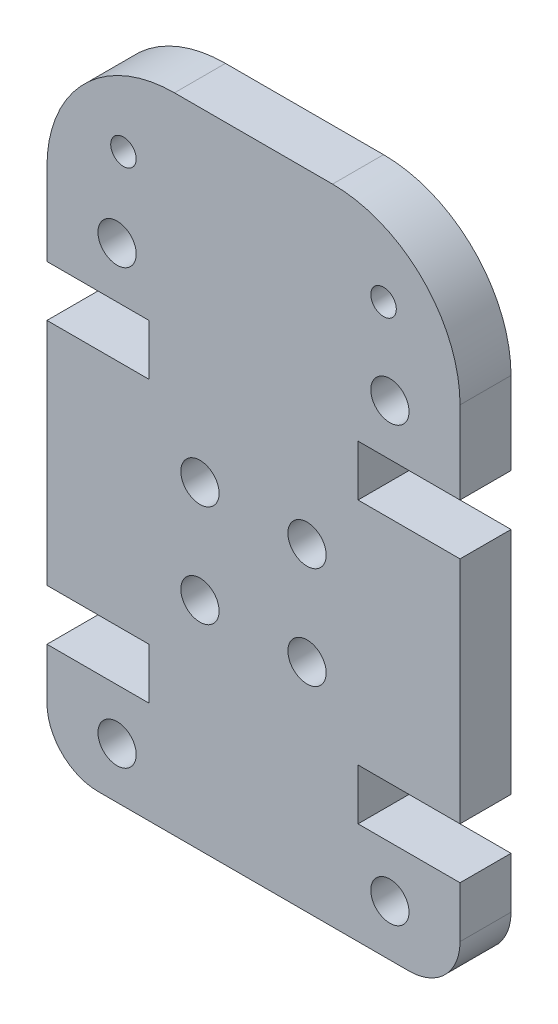
from build123d import *

# Parameters (mm, degrees)
SKETCH1_R           = 0.75
SKETCH1_R_2         = 0.5
BOSS_EXTRUDE1_DEPTH = 2


with BuildPart() as part:
    # Sketch1 → Boss-Extrude1 (new body)
    with BuildSketch(Plane.XY):
        with BuildLine():
            Line((12.2, 4), (16.2, 4))
            Line((16.2, 4), (16.2, 2))
            ThreePointArc((16.2, 2), (15.614213562, 0.585786438), (14.2, 0))
            Line((14.2, 0), (2, 0))
            ThreePointArc((2, 0), (0.585786438, 0.585786438), (0, 2))
            Line((0, 2), (0, 4))
            Line((0, 4), (4, 4))
            Line((4, 4), (4, 6))
            Line((4, 6), (0, 6))
            Line((0, 6), (0, 15))
            Line((0, 15), (4, 15))
            Line((4, 15), (4, 17))
            Line((4, 17), (0, 17))
            Line((0, 17), (0, 20.23))
            ThreePointArc((0, 20.23), (1.464466094, 23.765533906), (5, 25.23))
            Line((5, 25.23), (11.2, 25.23))
            ThreePointArc((11.2, 25.23), (14.735533906, 23.765533906), (16.2, 20.23))
            Line((16.2, 20.23), (16.2, 17))
            Line((16.2, 17), (12.2, 17))
            Line((12.2, 17), (12.2, 15))
            Line((12.2, 15), (16.2, 15))
            Line((16.2, 15), (16.2, 6))
            Line((16.2, 6), (12.2, 6))
            Line((12.2, 6), (12.2, 4))
        make_face()
        with Locations((13.45, 2)):
            Circle(SKETCH1_R, mode=Mode.SUBTRACT)
        with Locations((13.2, 22.23)):
            Circle(SKETCH1_R_2, mode=Mode.SUBTRACT)
        with Locations((10.2, 8.5)):
            Circle(SKETCH1_R, mode=Mode.SUBTRACT)
        with Locations((13.45, 19)):
            Circle(SKETCH1_R, mode=Mode.SUBTRACT)
        with Locations((10.2, 12.5)):
            Circle(SKETCH1_R, mode=Mode.SUBTRACT)
        with Locations((6, 12.5)):
            Circle(SKETCH1_R, mode=Mode.SUBTRACT)
        with Locations((2.75, 19)):
            Circle(SKETCH1_R, mode=Mode.SUBTRACT)
        with Locations((6, 8.5)):
            Circle(SKETCH1_R, mode=Mode.SUBTRACT)
        with Locations((3, 22.23)):
            Circle(SKETCH1_R_2, mode=Mode.SUBTRACT)
        with Locations((2.75, 2)):
            Circle(SKETCH1_R, mode=Mode.SUBTRACT)
    extrude(amount=BOSS_EXTRUDE1_DEPTH)


solid = part.part
